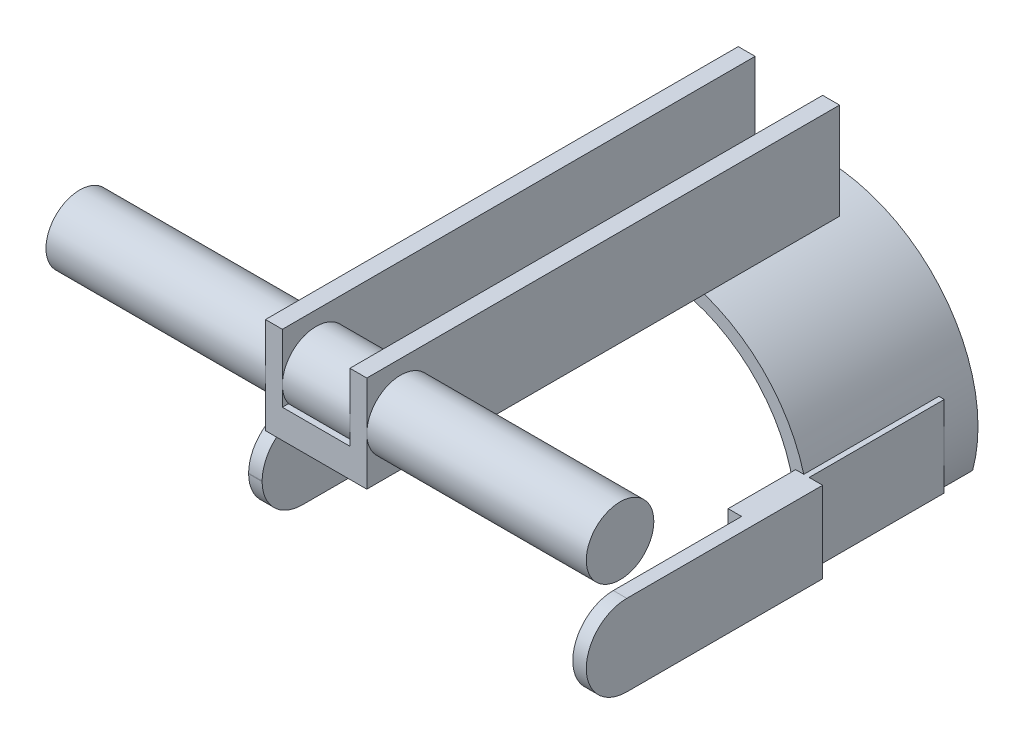
from build123d import *

# Parameters (mm, degrees)
EXTRUDE_1_DEPTH     = 50
SKETCH_3_W          = 4
SKETCH_3_H          = 24
EXTRUDE_2_DEPTH     = 70
SKETCH_5_R          = 80
SKETCH_5_R_2        = 46
CUT_EXTRUDE_2_DEPTH = 10
EXTRUDE_4_DEPTH     = 140
SKETCH_10_R         = 10
EXTRUDE_5_DEPTH     = 80
SKETCH_12_W         = 4
SKETCH_12_H         = 70
EXTRUDE_6_DEPTH     = 24
CUT_EXTRUDE_3_DEPTH = 131


with BuildPart() as part:
    # 草图2 → 凸台-拉伸1 (new body)
    with BuildSketch(Plane.XY):
        with BuildLine():
            Line((-46, 0), (-42, 0))
            ThreePointArc((-42, 0), (0, 42), (42, 0))
            Line((42, 0), (46, 0))
            ThreePointArc((46, 0), (37.456641601, 26.702059846), (15, 43.48562981))
            Line((15, 43.48562981), (15, 72))
            Line((15, 72), (10, 72))
            Line((10, 72), (10, 52))
            Line((10, 52), (-10, 52))
            Line((-10, 52), (-10, 72))
            Line((-10, 72), (-15, 72))
            Line((-15, 72), (-15, 43.48562981))
            ThreePointArc((-15, 43.48562981), (-37.456641601, 26.702059846), (-46, 0))
        make_face()
    extrude(amount=EXTRUDE_1_DEPTH)

    # 草图3 → 凸台-拉伸2 (add)
    with BuildSketch(Plane(origin=(0, 0, 0), x_dir=(-1, 0, 0), z_dir=(0, 0, -1))):
        with Locations((-44, 0)):
            Rectangle(SKETCH_3_W, SKETCH_3_H)
        with Locations((44, 0)):
            Rectangle(SKETCH_3_W, SKETCH_3_H)
    extrude(amount=-EXTRUDE_2_DEPTH)

    # 草图5 → 切除-拉伸2 (cut)
    with BuildSketch(Plane(origin=(0, 0, 0), x_dir=(-1, 0, 0), z_dir=(0, 0, -1))):
        Circle(SKETCH_5_R)
        Circle(SKETCH_5_R_2, mode=Mode.SUBTRACT)
    extrude(amount=-CUT_EXTRUDE_2_DEPTH, mode=Mode.SUBTRACT)

    # 草图9 → 凸台-拉伸4 (add)
    with BuildSketch(Plane(origin=(0, 0, 10), x_dir=(-1, 0, 0), z_dir=(0, 0, -1))):
        Polygon((-15, 72), (-15, 43.48562981), (15, 43.48562981), (15, 72), (10, 72), (10, 52), (-10, 52), (-10, 72), align=None)
    extrude(amount=-EXTRUDE_4_DEPTH)

    # 草图10 → 凸台-拉伸5 (add, symmetric)
    with BuildSketch(Plane(origin=(0, 0, 0), x_dir=(0, 0, -1), z_dir=(1, 0, 0))):
        with Locations((-140, 57.742814905)):
            Circle(SKETCH_10_R)
    extrude(amount=EXTRUDE_5_DEPTH, both=True)

    # 草图12 → 凸台-拉伸6 (add)
    with BuildSketch(Plane.XZ.offset(12)):
        with Locations((-48, 84.999732959)):
            Rectangle(SKETCH_12_W, SKETCH_12_H)
        with Locations((48, 85)):
            Rectangle(SKETCH_12_W, SKETCH_12_H)
    extrude(amount=-EXTRUDE_6_DEPTH)

    # 草图13 → 切除-拉伸3 (cut, through all)
    with BuildSketch(Plane.ZY.offset(50)):
        with BuildLine():
            Line((108, 12), (128.196913472, 12))
            Line((128.196913472, 12), (128.196913472, -12))
            Line((128.196913472, -12), (108, -12))
            ThreePointArc((108, -12), (120, 0), (108, 12))
        make_face()
    extrude(amount=-CUT_EXTRUDE_3_DEPTH, mode=Mode.SUBTRACT)


solid = part.part
